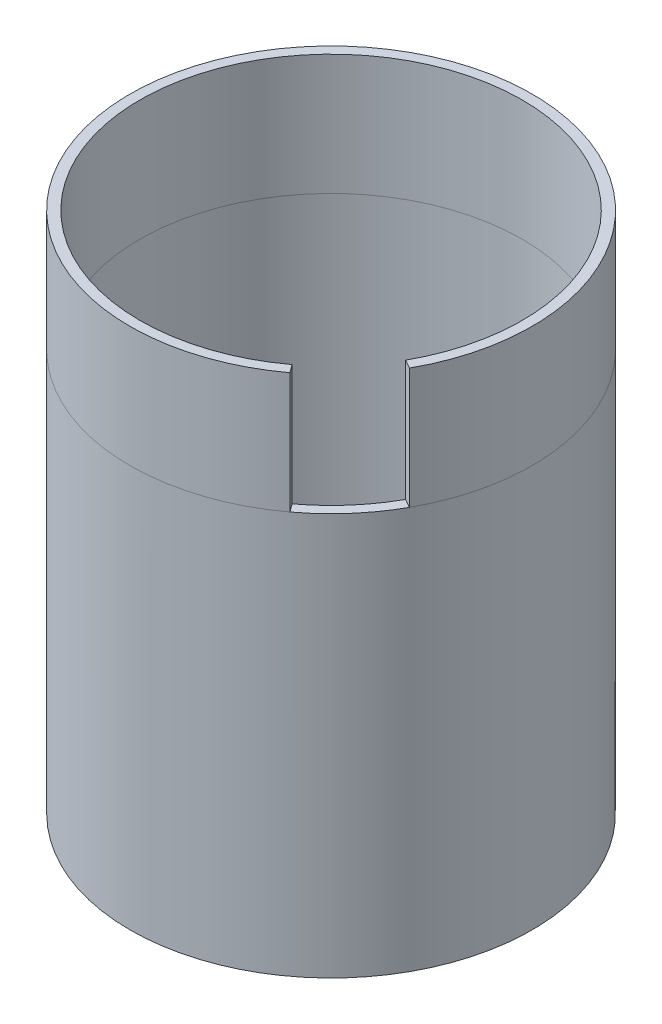
from build123d import *

# Parameters (mm, degrees)
SKETCH_1_R      = 5
SKETCH_1_R_2    = 4.75
EXTRUDE_3_DEPTH = 10
EXTRUDE_5_DEPTH = 3


with BuildPart() as part:
    # 草圖1 → 填料-伸長3 (new body)
    with BuildSketch(Plane(origin=(0, 0, 0), x_dir=(1, 0, 0), z_dir=(0, 1, 0))):
        with Locations(Location((0, 0, 0), (0, 0, 270))):
            Circle(SKETCH_1_R)
        with Locations(Location((0, 0, 0), (0, 0, 270))):
            Circle(SKETCH_1_R_2, mode=Mode.SUBTRACT)
    extrude(amount=EXTRUDE_3_DEPTH)

    # 草圖2 → 填料-伸長5 (add)
    with BuildSketch(Plane(origin=(0, 10, 0), x_dir=(1, 0, 0), z_dir=(0, 1, 0))):
        with BuildLine():
            Line((2.838234404, -3.808795803), (2.987635913, -4.009243277))
            ThreePointArc((2.987635913, -4.009243277), (-3.76819109, 3.293473376), (4.37304783, -2.424139574))
            Line((4.37304783, -2.424139574), (4.154407358, -2.302911094))
            ThreePointArc((4.154407358, -2.302911094), (-3.579955501, 3.128951756), (2.838234404, -3.808795803))
        make_face()
    extrude(amount=EXTRUDE_5_DEPTH)


solid = part.part
